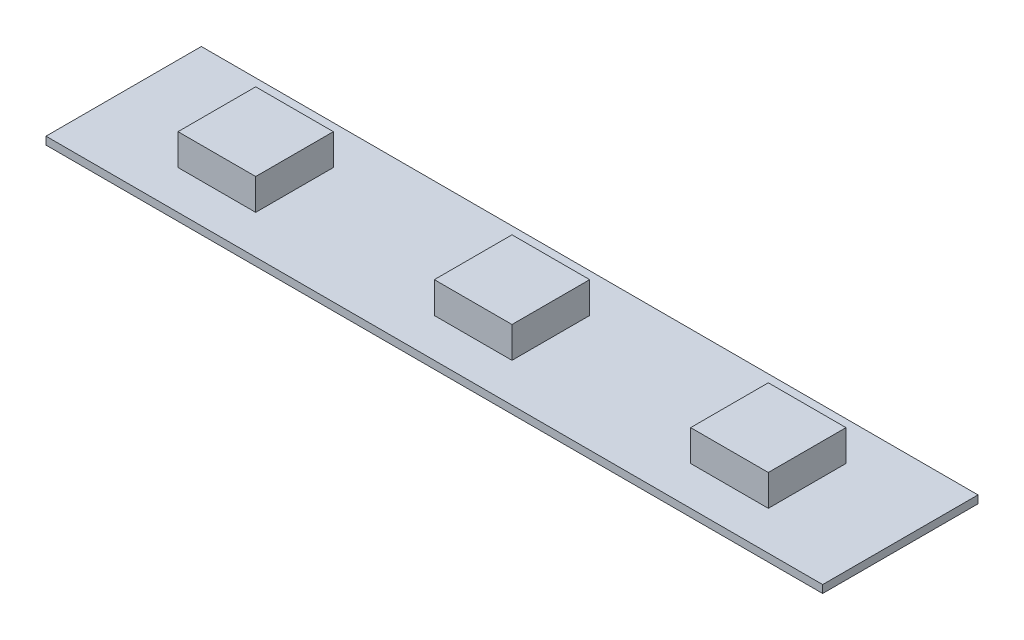
from build123d import *

# Parameters (mm, degrees)
SKETCH1_W            = 50
SKETCH1_H            = 10
BOSS_EXTRUDE1_DEPTH  = 0.5
SKETCH12_W           = 5
SKETCH12_H           = 5
BOSS_EXTRUDE8_DEPTH  = 2
SKETCH13_W           = 5
SKETCH13_H           = 5
BOSS_EXTRUDE9_DEPTH  = 2
SKETCH14_W           = 5
SKETCH14_H           = 5
BOSS_EXTRUDE10_DEPTH = 2


with BuildPart() as part:
    # Sketch1 → Boss-Extrude1 (new body)
    with BuildSketch(Plane(origin=(0, 0, 0), x_dir=(1, 0, 0), z_dir=(0, 1, 0))):
        Rectangle(SKETCH1_W, SKETCH1_H)
    extrude(amount=BOSS_EXTRUDE1_DEPTH)

    # Sketch12 → Boss-Extrude8 (add)
    with BuildSketch(Plane(origin=(0, 0.5, 0), x_dir=(1, 0, 0), z_dir=(0, 1, 0))):
        with Locations((-16.500638267, 0)):
            Rectangle(SKETCH12_W, SKETCH12_H)
    extrude(amount=BOSS_EXTRUDE8_DEPTH)

    # Sketch13 → Boss-Extrude9 (add)
    with BuildSketch(Plane(origin=(0, 0.5, 0), x_dir=(1, 0, 0), z_dir=(0, 1, 0))):
        Rectangle(SKETCH13_W, SKETCH13_H)
    extrude(amount=BOSS_EXTRUDE9_DEPTH)

    # Sketch14 → Boss-Extrude10 (add)
    with BuildSketch(Plane(origin=(0, 0.5, 0), x_dir=(1, 0, 0), z_dir=(0, 1, 0))):
        with Locations((16.500638267, 0)):
            Rectangle(SKETCH14_W, SKETCH14_H)
    extrude(amount=BOSS_EXTRUDE10_DEPTH)


solid = part.part
